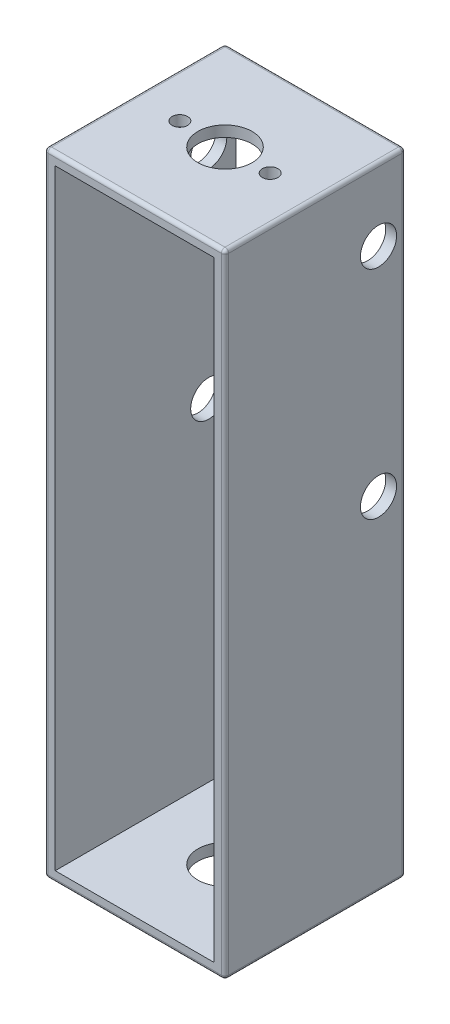
from build123d import *

# Parameters (mm, degrees)
SKETCH1_W           = 50
SKETCH1_H           = 50
BOSS_EXTRUDE1_DEPTH = 175
SHELL1_T            = -3
CUT_EXTRUDE1_REACH  = 180.536
SKETCH2_R           = 7.5
SKETCH2_R_2         = 2.15
SKETCH2_2_R         = 7.5
CUT_EXTRUDE2_DEPTH  = 179.535710714
SKETCH3_R           = 5
CUT_EXTRUDE3_DEPTH  = 184.711730709
FILLET1_R           = 1


with BuildPart() as part:
    # Sketch1 → Boss-Extrude1 (new body)
    with BuildSketch(Plane(origin=(0, 0, 0), x_dir=(1, 0, 0), z_dir=(0, 1, 0))):
        Rectangle(SKETCH1_W, SKETCH1_H)
    extrude(amount=-BOSS_EXTRUDE1_DEPTH)

    # Shell1
    shell1_openings = [part.faces().sort_by_distance(p)[0] for p in [
        (0, -87.5, -25),
        (0, -87.5, 25),
    ]]
    offset(amount=SHELL1_T, openings=shell1_openings, kind=Kind.INTERSECTION)

    # Sketch2 → Cut-Extrude1 (cut, up to next)
    with BuildSketch(Plane(origin=(0, 0, 0), x_dir=(1, 0, 0), z_dir=(0, 1, 0)), mode=Mode.PRIVATE) as cut_extrude1_sk1:
        Circle(SKETCH2_R)
    cut_extrude1_tool1 = extrude(cut_extrude1_sk1.sketch, amount=-CUT_EXTRUDE1_REACH, mode=Mode.PRIVATE) & part.part
    # Sketch2 → Cut-Extrude1 (cut, up to next)
    with BuildSketch(Plane(origin=(0, 0, 0), x_dir=(1, 0, 0), z_dir=(0, 1, 0)), mode=Mode.PRIVATE) as cut_extrude1_sk2:
        with Locations((-12.5, 0)):
            Circle(SKETCH2_R_2)
    cut_extrude1_tool2 = extrude(cut_extrude1_sk2.sketch, amount=-CUT_EXTRUDE1_REACH, mode=Mode.PRIVATE) & part.part
    # Sketch2 → Cut-Extrude1 (cut, up to next)
    with BuildSketch(Plane(origin=(0, 0, 0), x_dir=(1, 0, 0), z_dir=(0, 1, 0)), mode=Mode.PRIVATE) as cut_extrude1_sk3:
        with Locations((12.5, 0)):
            Circle(SKETCH2_R_2)
    cut_extrude1_tool3 = extrude(cut_extrude1_sk3.sketch, amount=-CUT_EXTRUDE1_REACH, mode=Mode.PRIVATE) & part.part
    add(cut_extrude1_tool1.solids().sort_by_distance((0, 0, 0))[0], mode=Mode.SUBTRACT)
    add(cut_extrude1_tool2.solids().sort_by_distance((-12.5, 0, 0))[0], mode=Mode.SUBTRACT)
    add(cut_extrude1_tool3.solids().sort_by_distance((12.5, 0, 0))[0], mode=Mode.SUBTRACT)

    # Sketch2_2 → Cut-Extrude2 (cut, through all)
    with BuildSketch(Plane(origin=(0, 0, 0), x_dir=(1, 0, 0), z_dir=(0, 1, 0))):
        Circle(SKETCH2_2_R)
    extrude(amount=-CUT_EXTRUDE2_DEPTH, mode=Mode.SUBTRACT)

    # Sketch3 → Cut-Extrude3 (cut, through all)
    with BuildSketch(Plane(origin=(25, 0, 0), x_dir=(0, 0, -1), z_dir=(1, 0, 0))):
        with Locations((17.5, -20)):
            Circle(SKETCH3_R)
        with Locations((17.5, -80)):
            Circle(SKETCH3_R)
    extrude(amount=-CUT_EXTRUDE3_DEPTH, mode=Mode.SUBTRACT)

    # Fillet1
    fillet1_edges = [part.edges().sort_by_distance(p)[0] for p in [
        (-25, -175, 0),
        (0, -175, -25),
        (25, -175, 0),
        (0, -175, 25),
        (25, -87.5, -25),
        (0, 0, -25),
        (-25, -87.5, -25),
        (-25, 0, 0),
        (-25, -87.5, 25),
        (25, -87.5, 25),
        (0, 0, 25),
        (25, 0, 0),
    ]]
    fillet(fillet1_edges, radius=FILLET1_R)


solid = part.part
